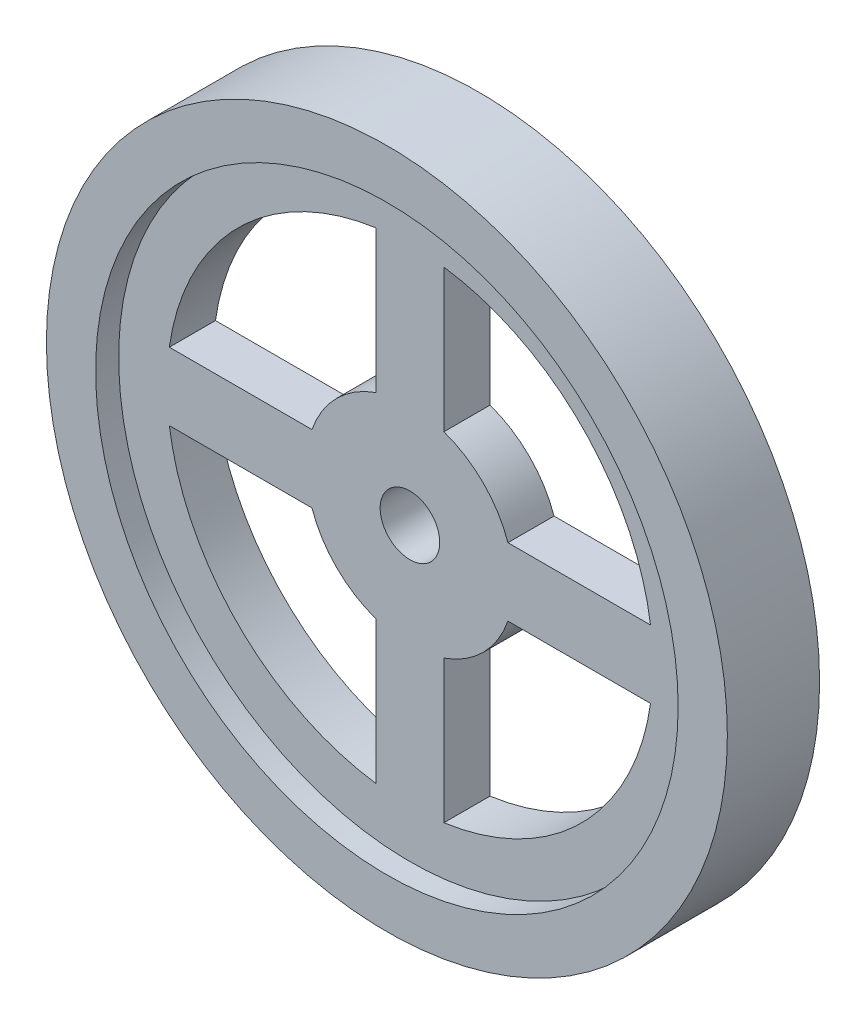
from build123d import *

# Parameters (mm, degrees)
SKETCH1_R                = 37.5
BOSS_EXTRUDE1_DEPTH      = 10.16
SKETCH2_R                = 32.081215916
CUT_EXTRUDE1_DEPTH       = 10.16
SKETCH4_R                = 32.081215916
BOSS_EXTRUDE3_DEPTH      = 2.54
BOSS_EXTRUDE3_DEPTH_BACK = 2.54
CUT_EXTRUDE2_DEPTH       = 15.24
SKETCH6_R                = 3.281091855
CUT_EXTRUDE3_DEPTH       = 15.24


with BuildPart() as part:
    # Sketch1 → Boss-Extrude1 (new body)
    with BuildSketch(Plane.XY):
        Circle(SKETCH1_R)
    extrude(amount=BOSS_EXTRUDE1_DEPTH)

    # Sketch2 → Cut-Extrude1 (cut)
    with BuildSketch(Plane.XY.offset(10.16)):
        Circle(SKETCH2_R)
    extrude(amount=-CUT_EXTRUDE1_DEPTH, mode=Mode.SUBTRACT)

    # Sketch4 → Boss-Extrude3 (add, two sides)
    with BuildSketch(Plane.XY.offset(5.08)) as boss_extrude3_sk:
        Circle(SKETCH4_R)
    extrude(amount=BOSS_EXTRUDE3_DEPTH)
    extrude(boss_extrude3_sk.sketch, amount=-BOSS_EXTRUDE3_DEPTH_BACK)

    # Sketch5 → Cut-Extrude2 (cut)
    with BuildSketch(Plane.XY.offset(7.62)):
        with BuildLine():
            Line((-3.738926609, 10.791901804), (-3.738926609, 26.50033006))
            ThreePointArc((-3.738926609, 26.50033006), (-18.924152101, 18.924152101), (-26.50033006, 3.738926609))
            Line((-26.50033006, 3.738926609), (-10.791901804, 3.738926609))
            ThreePointArc((-10.791901804, 3.738926609), (-8.076036055, 8.076036055), (-3.738926609, 10.791901804))
        make_face()
        with BuildLine():
            Line((3.738926609, 10.791901804), (3.738926609, 26.50033006))
            ThreePointArc((3.738926609, 26.50033006), (18.924152101, 18.924152101), (26.50033006, 3.738926609))
            Line((26.50033006, 3.738926609), (10.791901804, 3.738926609))
            ThreePointArc((10.791901804, 3.738926609), (8.076036055, 8.076036055), (3.738926609, 10.791901804))
        make_face()
        with BuildLine():
            Line((10.791901804, -3.738926609), (26.50033006, -3.738926609))
            ThreePointArc((26.50033006, -3.738926609), (18.924152101, -18.924152101), (3.738926609, -26.50033006))
            Line((3.738926609, -26.50033006), (3.738926609, -10.791901804))
            ThreePointArc((3.738926609, -10.791901804), (8.076036055, -8.076036055), (10.791901804, -3.738926609))
        make_face()
        with BuildLine():
            Line((-3.738926609, -10.791901804), (-3.738926609, -26.50033006))
            ThreePointArc((-3.738926609, -26.50033006), (-18.924152101, -18.924152101), (-26.50033006, -3.738926609))
            Line((-26.50033006, -3.738926609), (-10.791901804, -3.738926609))
            ThreePointArc((-10.791901804, -3.738926609), (-8.076036055, -8.076036055), (-3.738926609, -10.791901804))
        make_face()
    extrude(amount=-CUT_EXTRUDE2_DEPTH, mode=Mode.SUBTRACT)

    # Sketch6 → Cut-Extrude3 (cut)
    with BuildSketch(Plane.XY.offset(7.62)):
        Circle(SKETCH6_R)
    extrude(amount=-CUT_EXTRUDE3_DEPTH, mode=Mode.SUBTRACT)


solid = part.part
